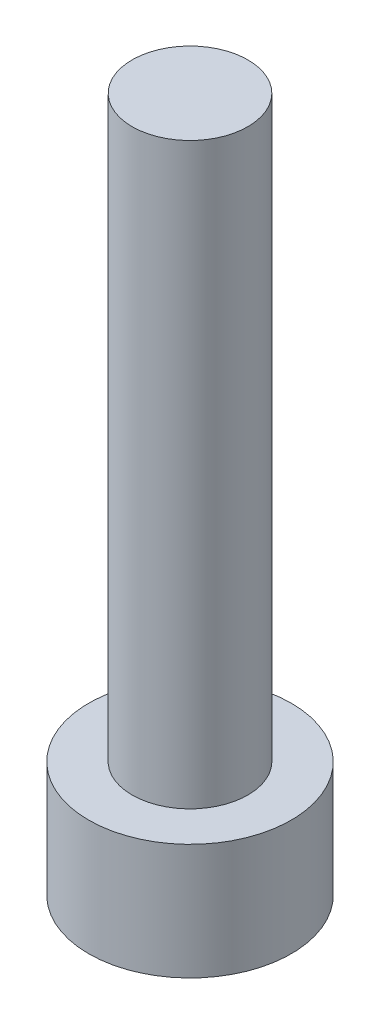
from build123d import *

# Parameters (mm, degrees)
SKETCH1_R           = 3.5
BOSS_EXTRUDE1_DEPTH = 4
SKETCH2_R           = 2
BOSS_EXTRUDE2_DEPTH = 20


with BuildPart() as part:
    # Sketch1 → Boss-Extrude1 (new body)
    with BuildSketch(Plane(origin=(0, 0, 0), x_dir=(1, 0, 0), z_dir=(0, 1, 0))):
        Circle(SKETCH1_R)
    extrude(amount=BOSS_EXTRUDE1_DEPTH)

    # Sketch2 → Boss-Extrude2 (add)
    with BuildSketch(Plane(origin=(0, 4, 0), x_dir=(1, 0, 0), z_dir=(0, 1, 0))):
        Circle(SKETCH2_R)
    extrude(amount=BOSS_EXTRUDE2_DEPTH)


solid = part.part
